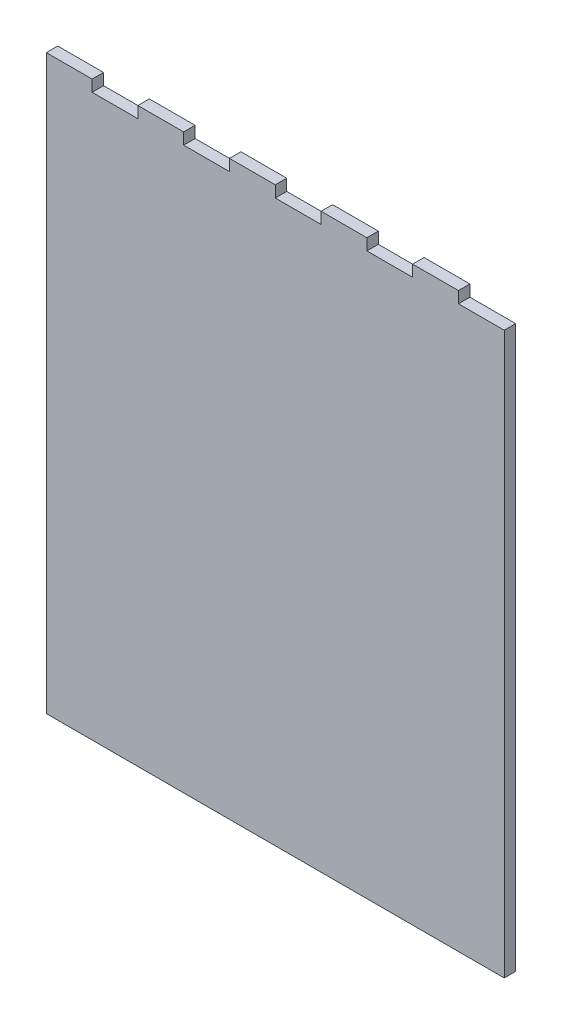
from build123d import *

# Parameters (mm, degrees)
SKETCH1_W           = 254
SKETCH1_H           = 317.5
BOSS_EXTRUDE1_DEPTH = 6.35
SKETCH2_W           = 25.4
SKETCH2_H           = 6.35
CUT_EXTRUDE1_DEPTH  = 6.35
LPATTERN1_COUNT     = 5
LPATTERN1_PITCH     = 50.8


with BuildPart() as part:
    # Sketch1 → Boss-Extrude1 (new body)
    with BuildSketch(Plane.XY):
        with Locations((127, 158.75)):
            Rectangle(SKETCH1_W, SKETCH1_H)
    extrude(amount=BOSS_EXTRUDE1_DEPTH)

    # Sketch2 → Cut-Extrude1 (cut)
    with BuildSketch(Plane.XY):
        with Locations((38.1, 314.325)):
            Rectangle(SKETCH2_W, SKETCH2_H)
    cut_extrude1 = extrude(amount=CUT_EXTRUDE1_DEPTH, mode=Mode.SUBTRACT)

    # LPattern1: Cut-Extrude1 ×5
    with Locations(*[(i * LPATTERN1_PITCH, 0, 0) for i in range(1, LPATTERN1_COUNT)]):
        add(cut_extrude1, mode=Mode.SUBTRACT)


solid = part.part
